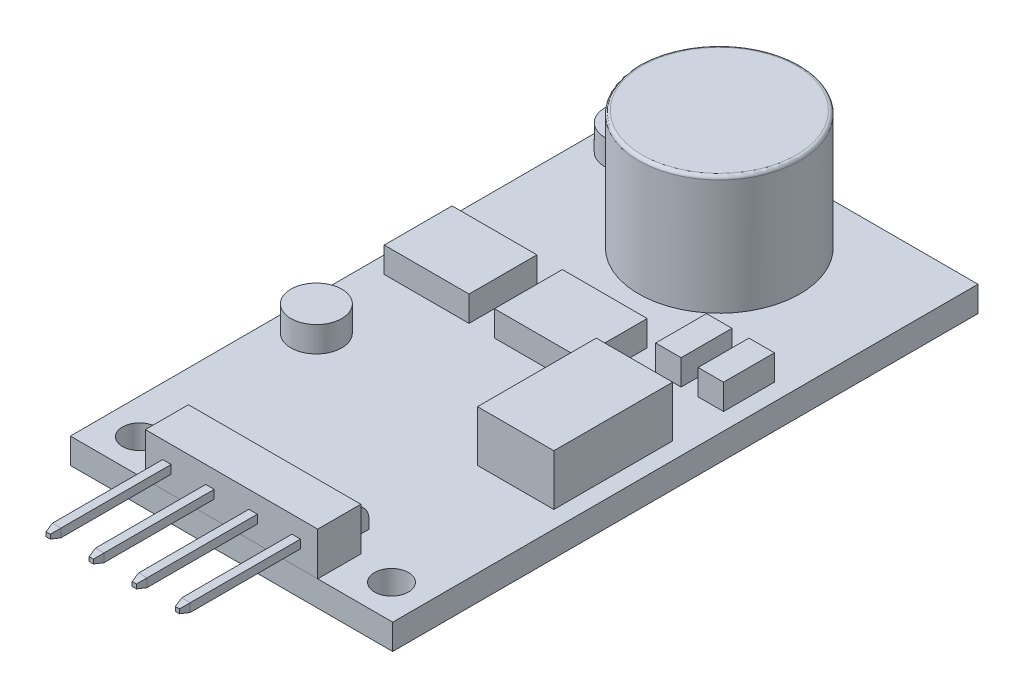
from build123d import *

# Parameters (mm, degrees)
SKETCH1_W             = 19
SKETCH1_H             = 34.5
BOSS_EXTRUDE1_DEPTH   = 1.5
SKETCH2_R             = 4.75
BOSS_EXTRUDE2_DEPTH   = 7
FILLET1_R             = 0.2
SKETCH3_R             = 1
CUT_EXTRUDE1_DEPTH    = 2.5
SKETCH4_W             = 4.5
SKETCH4_H             = 7
BOSS_EXTRUDE3_DEPTH   = 3
SKETCH5_R             = 1.5
SKETCH5_W             = 5
SKETCH5_H             = 4
SKETCH5_W_2           = 1.5
SKETCH5_H_2           = 3
BOSS_EXTRUDE4_DEPTH   = 1.5
SKETCH6_W             = 10.16
SKETCH6_H             = 2.54
BOSS_EXTRUDE5_DEPTH   = 2.54
BOSS_EXTRUDE7_START   = 1.27
BOSS_EXTRUDE7_DEPTH   = 0.25
CHAMFER1_SIZE         = 0.5
CHAMFER1_SIZE2        = 0.124664001
CHAMFER1_PART_2_SIZE  = 0.5
CHAMFER1_PART_2_SIZE2 = 0.124664001
CHAMFER1_PART_3_SIZE  = 0.5
CHAMFER1_PART_3_SIZE2 = 0.124664001
CHAMFER1_PART_4_SIZE  = 0.5
CHAMFER1_PART_4_SIZE2 = 0.124664001
LPATTERN1_COUNT       = 3
LPATTERN1_PITCH       = 2.54
LPATTERN1_2_COUNT     = 2
LPATTERN1_2_PITCH     = 2.54


with BuildPart() as part:
    # Sketch1 → Boss-Extrude1 (new body)
    with BuildSketch(Plane(origin=(0, 0, 0), x_dir=(1, 0, 0), z_dir=(0, 1, 0))):
        Rectangle(SKETCH1_W, SKETCH1_H)
    extrude(amount=BOSS_EXTRUDE1_DEPTH)

    # Sketch2 → Boss-Extrude2 (add)
    with BuildSketch(Plane(origin=(0, 1.5, 0), x_dir=(1, 0, 0), z_dir=(0, 1, 0))):
        with Locations((0, 11.5)):
            Circle(SKETCH2_R)
    extrude(amount=BOSS_EXTRUDE2_DEPTH)

    # Fillet1
    fillet1_edges = [part.edges().sort_by_distance(p)[0] for p in [
        (-4.75, 8.5, -11.5),
    ]]
    fillet(fillet1_edges, radius=FILLET1_R)

    # Sketch3 → Cut-Extrude1 (cut, through all)
    with BuildSketch(Plane(origin=(0, 1.5, 0), x_dir=(1, 0, 0), z_dir=(0, 1, 0))):
        with Locations((-7.43, -15.25)):
            Circle(SKETCH3_R)
        with Locations((7.43, -15.25)):
            Circle(SKETCH3_R)
    extrude(amount=-CUT_EXTRUDE1_DEPTH, mode=Mode.SUBTRACT)

    # Sketch4 → Boss-Extrude3 (add)
    with BuildSketch(Plane(origin=(0, 1.5, 0), x_dir=(1, 0, 0), z_dir=(0, 1, 0))):
        with Locations((6.25, -3.25)):
            Rectangle(SKETCH4_W, SKETCH4_H)
    extrude(amount=BOSS_EXTRUDE3_DEPTH)

    # Sketch5 → Boss-Extrude4 (add)
    with BuildSketch(Plane(origin=(0, 1.5, 0), x_dir=(1, 0, 0), z_dir=(0, 1, 0))):
        with Locations((-7.5, 13.75)):
            Circle(SKETCH5_R)
        with Locations((-7.5, -4.75)):
            Circle(SKETCH5_R)
        with Locations((-6, 2.25)):
            Rectangle(SKETCH5_W, SKETCH5_H)
        with Locations((0.5, 2.25)):
            Rectangle(SKETCH5_W, SKETCH5_H)
        with Locations((5.25, 4.75)):
            Rectangle(SKETCH5_W_2, SKETCH5_H_2)
        with Locations((7.75, 4.75)):
            Rectangle(SKETCH5_W_2, SKETCH5_H_2)
    extrude(amount=BOSS_EXTRUDE4_DEPTH)


with BuildPart() as body_2:
    # Sketch6 → Boss-Extrude5 (new body)
    with BuildSketch(Plane(origin=(0, 1.5, 0), x_dir=(1, 0, 0), z_dir=(0, 1, 0))):
        with Locations((0, -15.98)):
            Rectangle(SKETCH6_W, SKETCH6_H)
    extrude(amount=BOSS_EXTRUDE5_DEPTH)


with BuildPart() as body_3:
    # Sketch7 → Boss-Extrude7 (new body, symmetric)
    with BuildSketch(Plane(origin=(0, 0, 0), x_dir=(0, 0, -1), z_dir=(1, 0, 0)).offset(BOSS_EXTRUDE7_START)):
        with BuildLine():
            Line((-13.21, 1.5), (-13.21, 2.02))
            ThreePointArc((-13.21, 2.02), (-13.502893219, 2.727106781), (-14.21, 3.02))
            Line((-14.21, 3.02), (-24.25, 3.02))
            Line((-24.25, 3.02), (-24.25, 2.52))
            Line((-24.25, 2.52), (-14.21, 2.52))
            ThreePointArc((-14.21, 2.52), (-13.856446609, 2.373553391), (-13.71, 2.02))
            Line((-13.71, 2.02), (-13.71, 1.5))
            Line((-13.71, 1.5), (-13.21, 1.5))
        make_face()
    extrude(amount=BOSS_EXTRUDE7_DEPTH, both=True)

    # Chamfer1
    chamfer1_edges = [body_3.edges().sort_by_distance(p)[0] for p in [
        (1.27, 2.52, 24.25),
    ]]
    chamfer1_side = [body_3.faces().sort_by_distance(p)[0] for p in [
        (1.27, 2.52, 19.23),
    ]]
    chamfer(chamfer1_edges, length=CHAMFER1_SIZE, length2=CHAMFER1_SIZE2, reference=chamfer1_side[0])

    # Chamfer1 part 2
    chamfer1_part_2_edges = [body_3.edges().sort_by_distance(p)[0] for p in [
        (1.27, 3.02, 24.25),
    ]]
    chamfer1_part_2_side = [body_3.faces().sort_by_distance(p)[0] for p in [
        (1.27, 3.02, 19.23),
    ]]
    chamfer(chamfer1_part_2_edges, length=CHAMFER1_PART_2_SIZE, length2=CHAMFER1_PART_2_SIZE2, reference=chamfer1_part_2_side[0])

    # Chamfer1 part 3
    chamfer1_part_3_edges = [body_3.edges().sort_by_distance(p)[0] for p in [
        (1.52, 2.77, 24.25),
    ]]
    chamfer1_part_3_side = [body_3.faces().sort_by_distance(p)[0] for p in [
        (1.52, 2.699678586, 18.420858509),
    ]]
    chamfer(chamfer1_part_3_edges, length=CHAMFER1_PART_3_SIZE, length2=CHAMFER1_PART_3_SIZE2, reference=chamfer1_part_3_side[0])

    # Chamfer1 part 4
    chamfer1_part_4_edges = [body_3.edges().sort_by_distance(p)[0] for p in [
        (1.02, 2.77, 24.25),
    ]]
    chamfer1_part_4_side = [body_3.faces().sort_by_distance(p)[0] for p in [
        (1.02, 2.699678586, 18.420858509),
    ]]
    chamfer(chamfer1_part_4_edges, length=CHAMFER1_PART_4_SIZE, length2=CHAMFER1_PART_4_SIZE2, reference=chamfer1_part_4_side[0])


with BuildPart() as lpattern1_1:
    # LPattern1: pattern copy
    add(body_3.part.moved(Location(Vector(-1, 0, 0) * (1 * LPATTERN1_PITCH))))


with BuildPart() as lpattern1_2:
    # LPattern1: pattern copy
    add(body_3.part.moved(Location(Vector(-1, 0, 0) * (2 * LPATTERN1_PITCH))))


with BuildPart() as lpattern1_2_1:
    # LPattern1 2: pattern copy
    add(body_3.part.moved(Location(Vector(1, 0, 0) * (1 * LPATTERN1_2_PITCH))))


solid = Compound([part.part, body_2.part, body_3.part, lpattern1_1.part, lpattern1_2.part, lpattern1_2_1.part])
